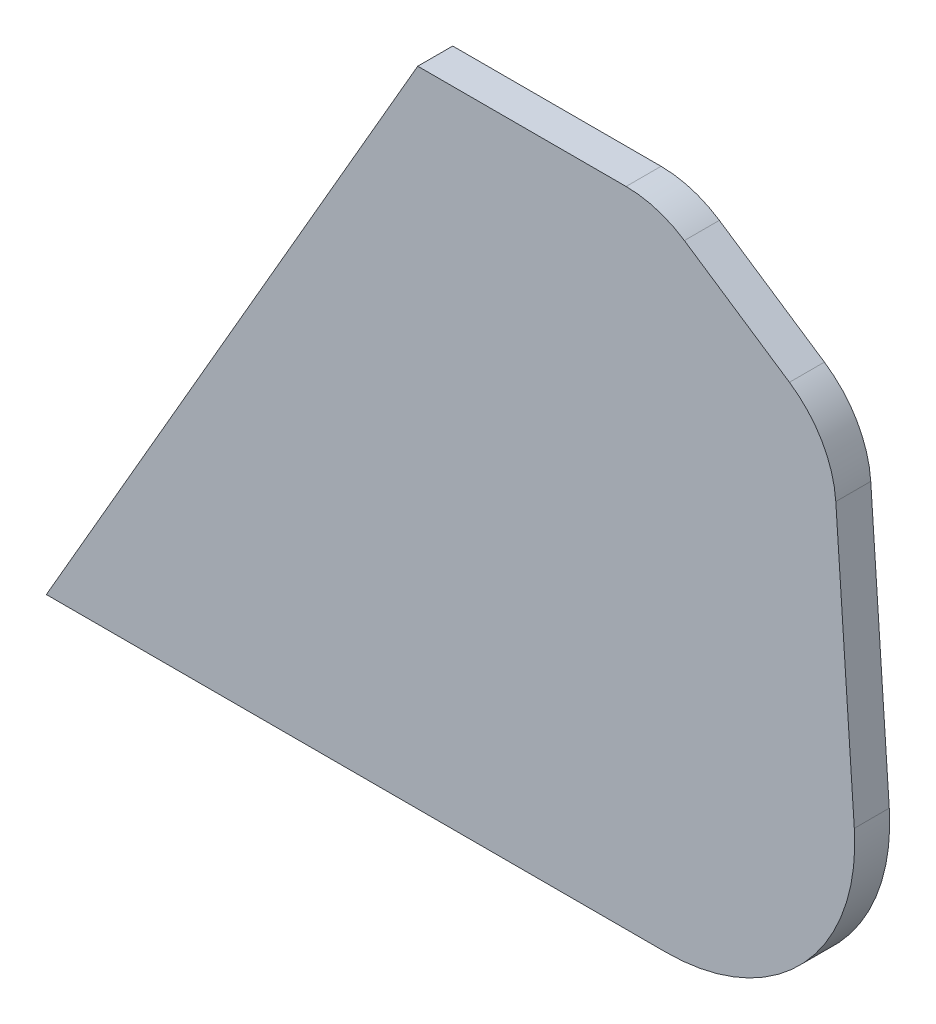
from build123d import *

# Parameters (mm, degrees)
BASE_EXTRUDE_DEPTH = 5


with BuildPart() as part:
    # Sketch2 → Base-Extrude (new body)
    with BuildSketch(Plane.XY):
        with BuildLine():
            Line((48.116224765, 92), (-5, 0))
            Line((-5, 0), (83.61203206, 0))
            ThreePointArc((83.61203206, 0), (103.33761172, 8.563582044), (110.550478804, 28.822110589))
            Line((110.550478804, 28.822110589), (107.902603037, 67.968834584))
            ThreePointArc((107.902603037, 67.968834584), (105.920101953, 74.468797721), (101.27285986, 79.426919569))
            Line((101.27285986, 79.426919569), (86.248315424, 89.470368646))
            ThreePointArc((86.248315424, 89.470368646), (82.267967787, 91.353667296), (77.912254854, 92))
            Line((77.912254854, 92), (48.116224765, 92))
        make_face()
    extrude(amount=BASE_EXTRUDE_DEPTH)


solid = part.part
